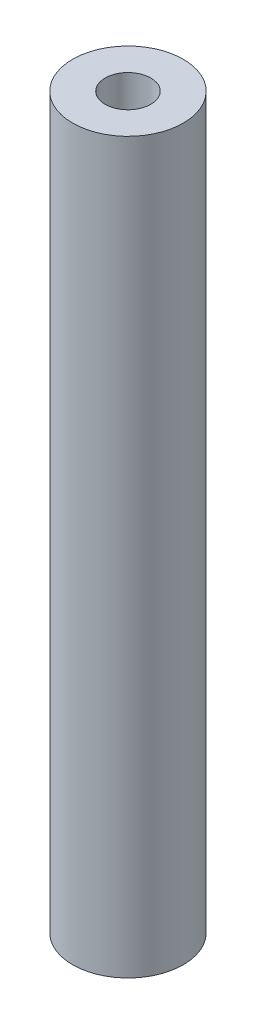
from build123d import *

# Parameters (mm, degrees)
SKETCH1_R                 = 4
BOSS_EXTRUDE1_DEPTH       = 26.35
M4X0_7_TAPPED_HOLE1_D     = 3.3
M4X0_7_TAPPED_HOLE1_DEPTH = 15
M4X0_7_TAPPED_HOLE1_TIP   = 0.991420021
M4X0_7_TAPPED_HOLE2_D     = 3.3
M4X0_7_TAPPED_HOLE2_DEPTH = 15
M4X0_7_TAPPED_HOLE2_TIP   = 0.991420021


with BuildPart() as part:
    # Sketch1 → Boss-Extrude1 (new body, symmetric)
    with BuildSketch(Plane(origin=(0, 0, 0), x_dir=(1, 0, 0), z_dir=(0, 1, 0))):
        Circle(SKETCH1_R)
    extrude(amount=BOSS_EXTRUDE1_DEPTH, both=True)

    # M4x0.7 Tapped Hole1
    with Locations(Plane(origin=(0, 26.35, 0), x_dir=(1, 0, 0), z_dir=(0, 1, 0))):
        with Locations((0, 0)):
            Hole(M4X0_7_TAPPED_HOLE1_D / 2, depth=M4X0_7_TAPPED_HOLE1_DEPTH)
            with Locations((0, 0, -(M4X0_7_TAPPED_HOLE1_DEPTH + M4X0_7_TAPPED_HOLE1_TIP / 2))):  # 118° drill point
                Cone(0, M4X0_7_TAPPED_HOLE1_D / 2, M4X0_7_TAPPED_HOLE1_TIP, mode=Mode.SUBTRACT)

    # M4x0.7 Tapped Hole2
    with Locations(Plane(origin=(0, -26.35, 0), x_dir=(-1, 0, 0), z_dir=(0, -1, 0))):
        with Locations((0, 0)):
            Hole(M4X0_7_TAPPED_HOLE2_D / 2, depth=M4X0_7_TAPPED_HOLE2_DEPTH)
            with Locations((0, 0, -(M4X0_7_TAPPED_HOLE2_DEPTH + M4X0_7_TAPPED_HOLE2_TIP / 2))):  # 118° drill point
                Cone(0, M4X0_7_TAPPED_HOLE2_D / 2, M4X0_7_TAPPED_HOLE2_TIP, mode=Mode.SUBTRACT)


solid = part.part
